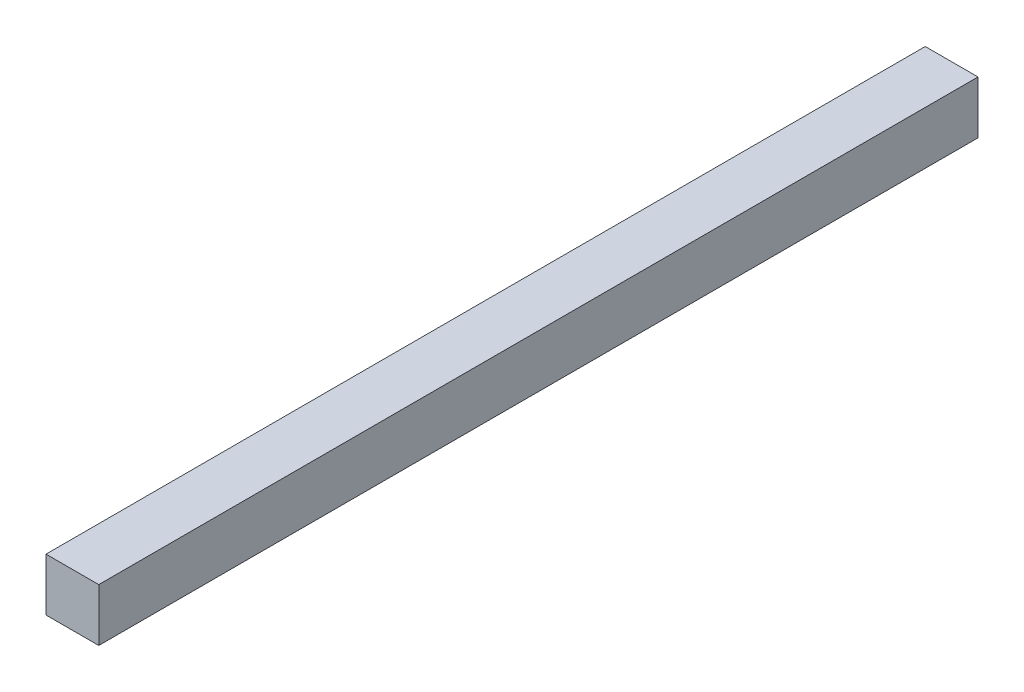
from build123d import *

# Parameters (mm, degrees)
SKETCH1_W           = 30
SKETCH1_H           = 30
BOSS_EXTRUDE1_DEPTH = 500


with BuildPart() as part:
    # Sketch1 → Boss-Extrude1 (new body)
    with BuildSketch(Plane.XY):
        Rectangle(SKETCH1_W, SKETCH1_H)
    extrude(amount=BOSS_EXTRUDE1_DEPTH)


solid = part.part
